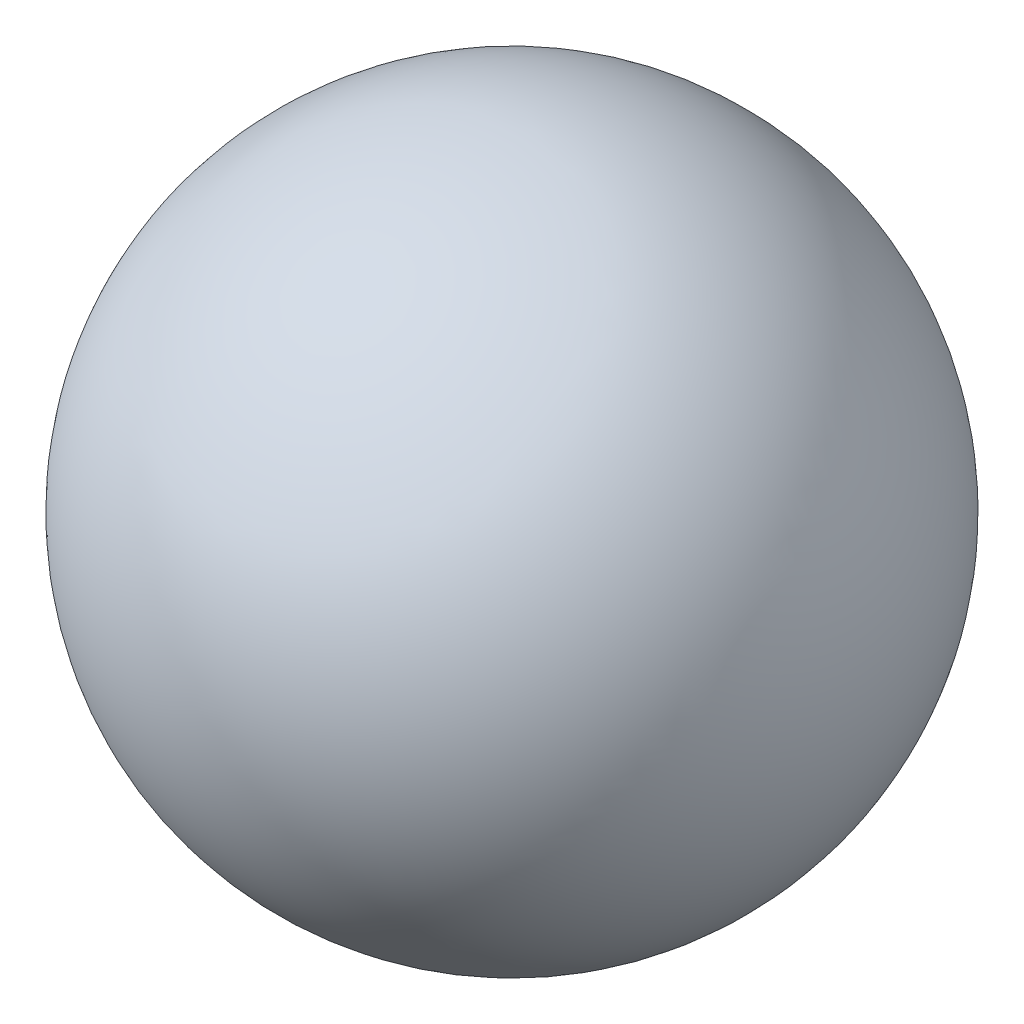
from build123d import *


with BuildPart() as part:
    # Sketch1 → Revolve1 (revolve)
    with BuildSketch(Plane.XY):
        with BuildLine():
            Line((-0.22, 0), (0.22, 0))
            ThreePointArc((0.22, 0), (0, -0.22), (-0.22, 0))
        make_face()
    revolve(axis=Axis((-0.22, 0, 0), (1, 0, 0)))


solid = part.part
